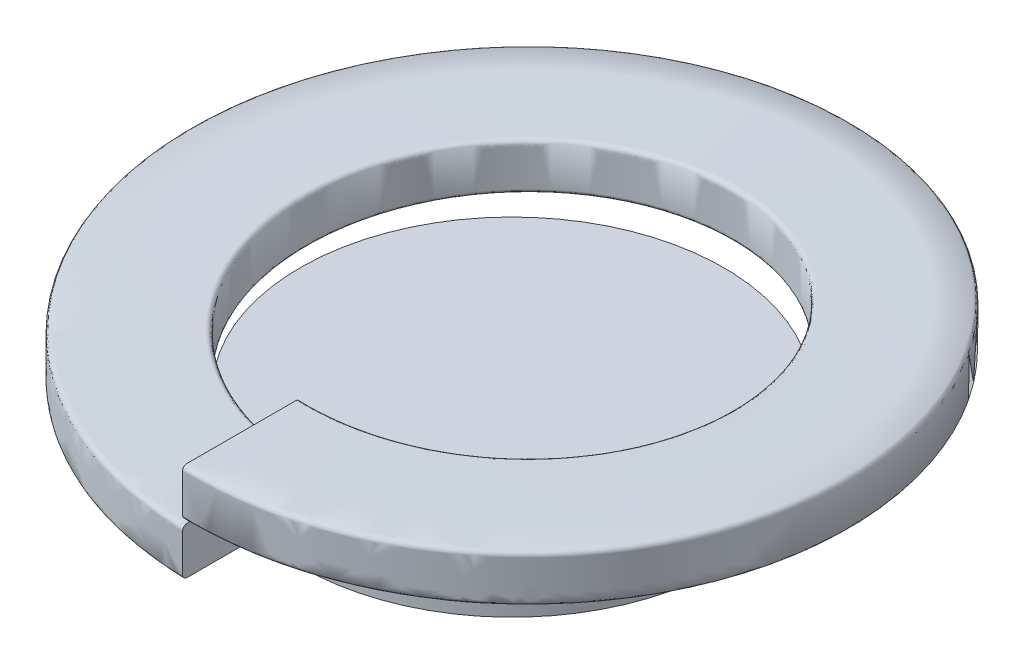
from build123d import *

# Parameters (mm, degrees)
SKETCH1_2_R = 4.5
THICKEN1_T2 = 1


with BuildPart() as part:
    # Sweep1: sweep along a curve in space
    with BuildLine() as sweep1_path:
        add(Edge.make_bspline(
            [(0, 0, 4.5), (-0.585276694, 0.022769921, 4.5), (-1.768621839, 0.068818105, 4.265693422), (-3.264361197, 0.137481751, 3.2648204), (-4.265816465, 0.20625489, 1.766908068), (-4.61712032, 0.27499869, 0), (-4.265702253, 0.343750351, -1.766908068), (-3.264818045, 0.412499906, -3.2648204), (-1.766908657, 0.481250023, -4.265693422), (0, 0.55, -4.617153289), (1.766908657, 0.618749977, -4.265693422), (3.264818045, 0.687500094, -3.2648204), (4.265702253, 0.756249649, -1.766908068), (4.61712032, 0.82500131, 0), (4.265816465, 0.89374511, 1.766908068), (3.264361197, 0.962518249, 3.2648204), (1.768621839, 1.031181895, 4.265693422), (0.585276694, 1.077230079, 4.5), (0, 1.1, 4.5)],
            knots=[0, 0, 0, 0, 0.0625, 0.125, 0.1875, 0.25, 0.3125, 0.375, 0.4375, 0.5, 0.5625, 0.625, 0.6875, 0.75, 0.8125, 0.875, 0.9375, 1, 1, 1, 1], degree=3))
    # Sketch2 → Sweep1 (sweep)
    with BuildSketch(Plane(origin=(0, 0, 0), x_dir=(0, 0, -1), z_dir=(1, 0, 0))):
        with BuildLine():
            Line((-4.6, 0), (-6.9, 0))
            ThreePointArc((-6.9, 0), (-6.970710678, 0.029289322), (-7, 0.1))
            Line((-7, 0.1), (-7, 0.9))
            ThreePointArc((-7, 0.9), (-6.970710678, 0.970710678), (-6.9, 1))
            Line((-6.9, 1), (-4.6, 1))
            ThreePointArc((-4.6, 1), (-4.529289322, 0.970710678), (-4.5, 0.9))
            Line((-4.5, 0.9), (-4.5, 0.1))
            ThreePointArc((-4.5, 0.1), (-4.529289322, 0.029289322), (-4.6, 0))
        make_face()
    sweep(path=sweep1_path.line, is_frenet=True)


with BuildPart() as body_2:
    # Sketch1_2 → Surface-Plane1: a flat surface bounded by the sketch
    with BuildSketch(Plane(origin=(0, 0, 0), x_dir=(1, 0, 0), z_dir=(0, 1, 0)), mode=Mode.PRIVATE) as surface_plane1_1_region:
        Circle(SKETCH1_2_R)
    surface_plane1_1 = surface_plane1_1_region.sketch.faces()[0]
    add(Solid.thicken(surface_plane1_1, -THICKEN1_T2))


solid = Compound([part.part, body_2.part])
